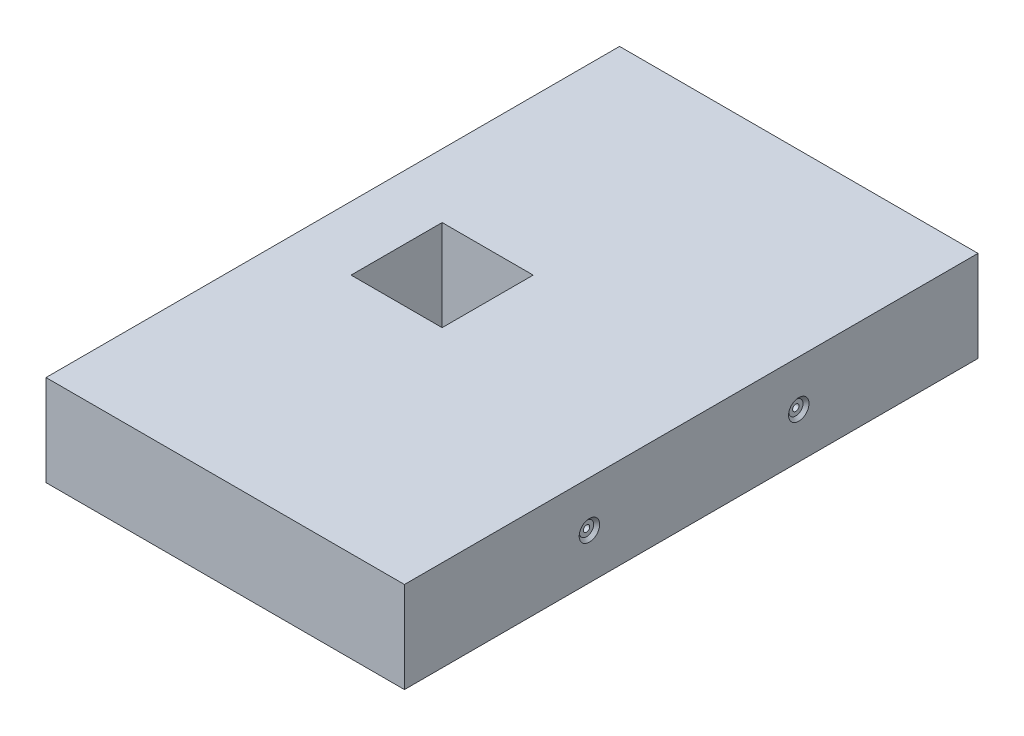
from build123d import *

# Parameters (mm, degrees)
SKETCH1_W                                   = 100
SKETCH1_H                                   = 160
SKETCH1_W_2                                 = 25.4
SKETCH1_H_2                                 = 25.4
BOSS_EXTRUDE1_DEPTH                         = 25.4
CBORE_FOR_0_BINDING_HEAD_MACHINE_SC_2_COUNT = 2
CBORE_FOR_0_BINDING_HEAD_MACHINE_SC_2_PITCH = 58.4


with BuildPart() as part:
    # Sketch1 → Boss-Extrude1 (new body)
    with BuildSketch(Plane(origin=(0, 0, 0), x_dir=(1, 0, 0), z_dir=(0, 1, 0))):
        Rectangle(SKETCH1_W, SKETCH1_H)
        with Locations((-19.49, 0)):
            Rectangle(SKETCH1_W_2, SKETCH1_H_2, mode=Mode.SUBTRACT)
    extrude(amount=BOSS_EXTRUDE1_DEPTH)

    # Sketch3 → CBORE for #0 Binding Head Machine Screw1 (revolve, cut)
    with BuildSketch(Plane(origin=(50, 12.7, 28.4), x_dir=(0, 0, -1), z_dir=(0, 1, 0))):
        Polygon((0, 0), (0, 30.53416509), (0.889, 30), (0.889, 0.8128), (1.98501, 0.8128), (1.98501, 0.87249), (2.8575, 0), align=None)
    cbore_for_0_binding_head_machine_screw1 = revolve(axis=Axis((56.35, 12.7, 28.4), (-1, 0, 0)), mode=Mode.SUBTRACT)

    # CBORE for _0 Binding Head Machine Sc 2: CBORE for #0 Binding Head Machine Screw1 ×2
    with Locations(*[(0, 0, -i * CBORE_FOR_0_BINDING_HEAD_MACHINE_SC_2_PITCH) for i in range(1, CBORE_FOR_0_BINDING_HEAD_MACHINE_SC_2_COUNT)]):
        add(cbore_for_0_binding_head_machine_screw1, mode=Mode.SUBTRACT)


solid = part.part
